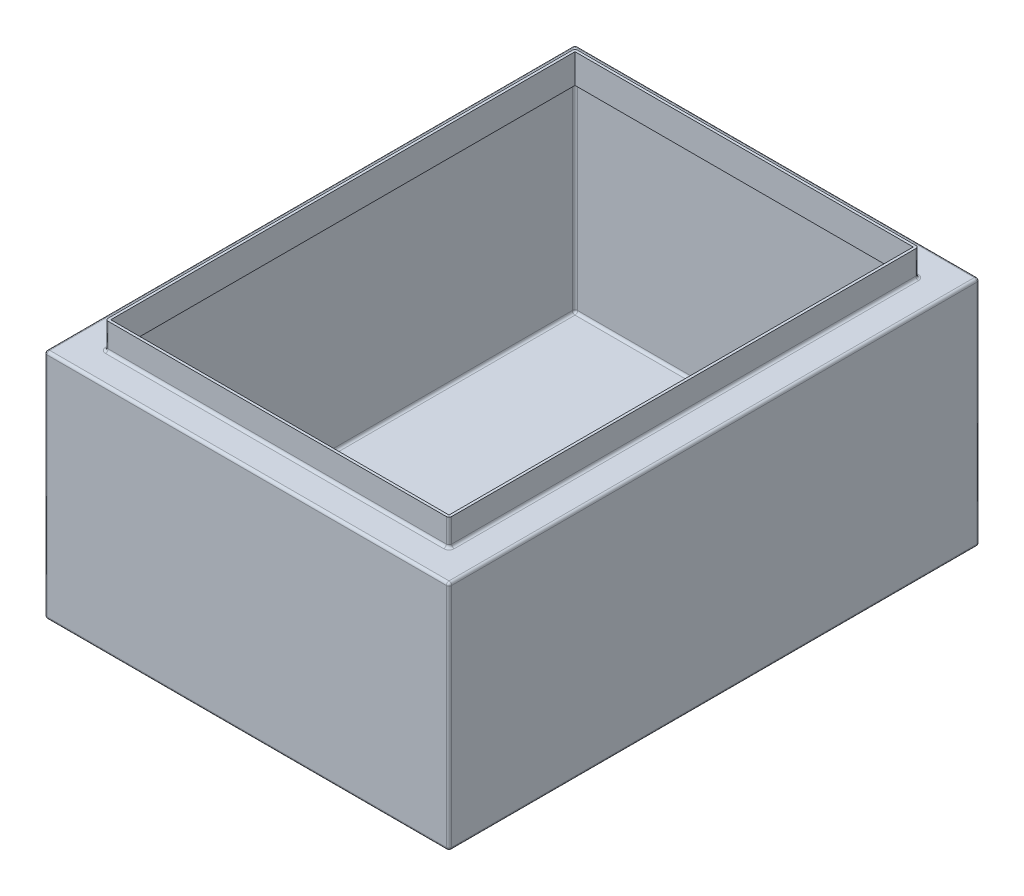
from build123d import *

# Parameters (mm, degrees)
SKETCH1_W           = 305
SKETCH1_H           = 400
BOSS_EXTRUDE1_DEPTH = 175
SHELL1_T            = 2
SKETCH2_W           = 255
SKETCH2_H           = 350
CUT_EXTRUDE1_DEPTH  = 5
SKETCH3_W           = 259
SKETCH3_H           = 354
SKETCH3_W_2         = 255
SKETCH3_H_2         = 350
BOSS_EXTRUDE2_DEPTH = 20
FILLET1_R           = 2


with BuildPart() as part:
    # Sketch1 → Boss-Extrude1 (new body)
    with BuildSketch(Plane(origin=(0, 0, 0), x_dir=(1, 0, 0), z_dir=(0, 1, 0))):
        with Locations((152.5, 200)):
            Rectangle(SKETCH1_W, SKETCH1_H)
    extrude(amount=BOSS_EXTRUDE1_DEPTH)

    # Shell1 (no face opened: a closed hollow body)
    add(offset(amount=-SHELL1_T, mode=Mode.PRIVATE), mode=Mode.SUBTRACT)

    # Sketch2 → Cut-Extrude1 (cut)
    with BuildSketch(Plane(origin=(0, 175, 0), x_dir=(1, 0, 0), z_dir=(0, 1, 0))):
        with Locations((152.5, 200)):
            Rectangle(SKETCH2_W, SKETCH2_H)
    extrude(amount=-CUT_EXTRUDE1_DEPTH, mode=Mode.SUBTRACT)

    # Sketch3 → Boss-Extrude2 (add)
    with BuildSketch(Plane(origin=(0, 175, 0), x_dir=(1, 0, 0), z_dir=(0, 1, 0))):
        with Locations((152.5, 200)):
            Rectangle(SKETCH3_W, SKETCH3_H)
        with Locations((152.5, 200)):
            Rectangle(SKETCH3_W_2, SKETCH3_H_2, mode=Mode.SUBTRACT)
    extrude(amount=BOSS_EXTRUDE2_DEPTH)

    # Fillet1
    fillet1_edges = [part.edges().sort_by_distance(p)[0] for p in [
        (305, 175, -200),
        (2, 2, -200),
        (2, 87.5, -398),
        (152.5, 2, -2),
        (2, 87.5, -2),
        (303, 2, -200),
        (303, 87.5, -2),
        (152.5, 2, -398),
        (303, 87.5, -398),
        (2, 173, -200),
        (152.5, 173, -2),
        (303, 173, -200),
        (152.5, 173, -398),
        (152.5, 175, -400),
        (23, 175, -200),
        (0, 175, -200),
        (152.5, 0, -400),
        (23, 185, -377),
        (152.5, 175, -23),
        (23, 185, -23),
        (282, 175, -200),
        (282, 185, -23),
        (152.5, 175, -377),
        (282, 185, -377),
        (305, 0, -200),
        (152.5, 0, 0),
        (0, 0, -200),
        (0, 87.5, -400),
        (305, 87.5, -400),
        (305, 87.5, 0),
        (0, 87.5, 0),
        (152.5, 175, 0),
    ]]
    fillet(fillet1_edges, radius=FILLET1_R)


solid = part.part
